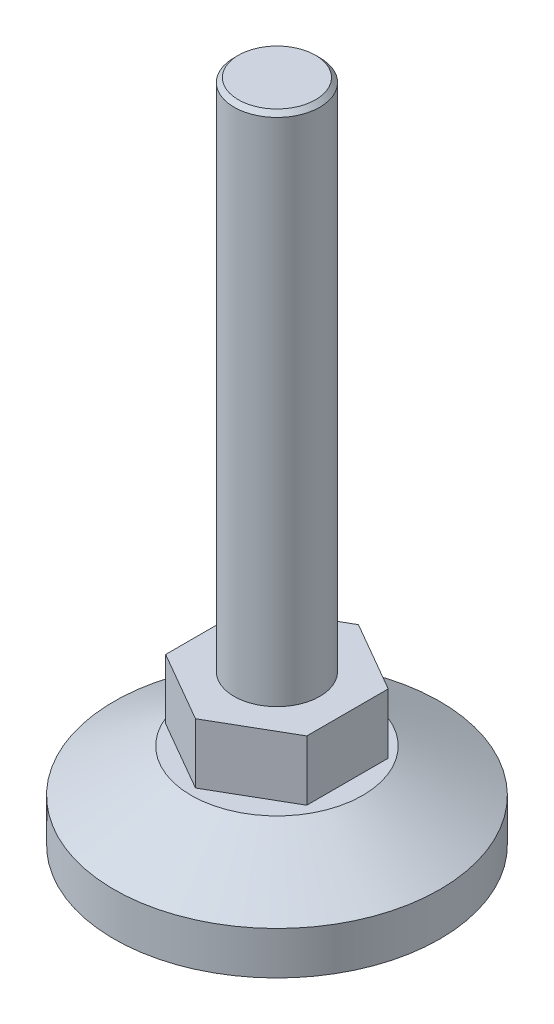
from build123d import *

# Parameters (mm, degrees)
CHAMFER_1_SIZE      = 0.5
CUT_EXTRUDE_START   = -7
SKETCH_2_R          = 12.139773641
CUT_EXTRUDE_1_DEPTH = 7


with BuildPart() as part:
    # Эскиз1 → Повернуть1 (revolve)
    with BuildSketch(Plane.XY, mode=Mode.PRIVATE) as revolve_1_sk:
        Polygon((0, 77.5), (-5, 77.5), (-5, 17.5), (-9.5, 17.5), (-9.5, 10.5), (-5, 10.5), (-5, 10), (-10, 10), (-19, 5), (-19, 0), (-5, 0), (-5, 7), (0, 7), align=None)
    revolve(revolve_1_sk.sketch.rotate(Axis((0, 0, 0), (0, 1, 0)), 180), axis=Axis((0, 0, 0), (0, 1, 0)))  # turned: the seam where the file's is

    # Фаска1
    chamfer_1_edges = [part.edges().sort_by_distance(p)[0] for p in [
        (-5, 77.5, 0),
    ]]
    chamfer(chamfer_1_edges, length=CHAMFER_1_SIZE)

    # Эскиз2 → Вырез-Вытянуть1 (cut)
    with BuildSketch(Plane(origin=(0, 17.5, 0), x_dir=(1, 0, 0), z_dir=(0, 1, 0)).offset(CUT_EXTRUDE_START)):
        Circle(SKETCH_2_R)
        Polygon((0, 9.5), (-8.227241336, 4.75), (-8.227241336, -4.75), (0, -9.5), (8.227241336, -4.75), (8.227241336, 4.75), align=None, mode=Mode.SUBTRACT)
    extrude(amount=CUT_EXTRUDE_1_DEPTH, mode=Mode.SUBTRACT)


solid = part.part
